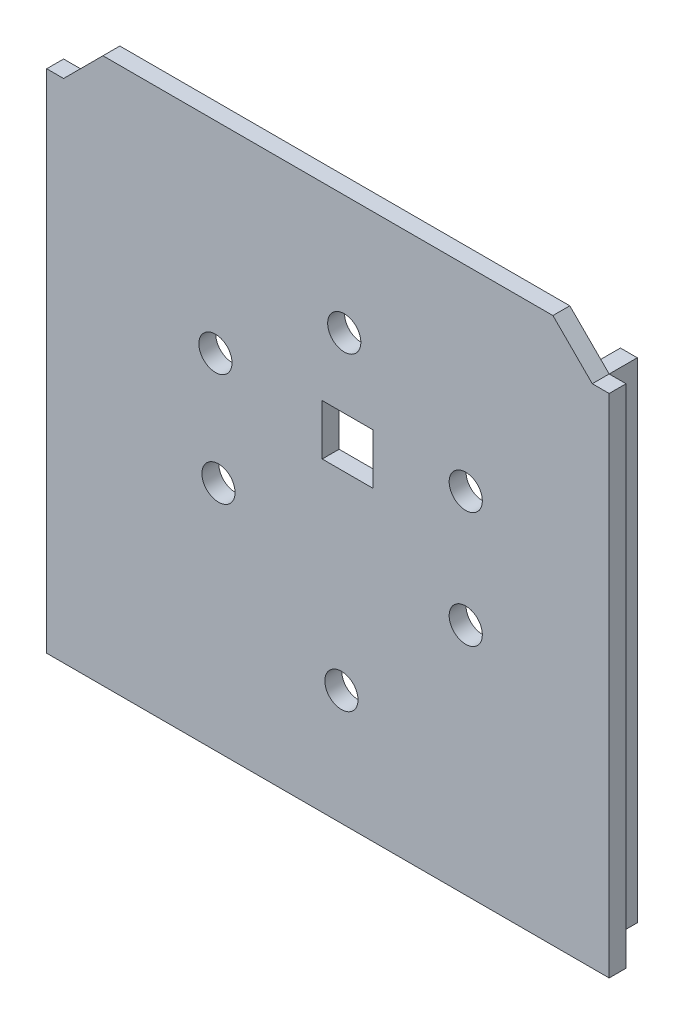
from build123d import *

# Parameters (mm, degrees)
CROQUIS1_R              = 2.950001172
CROQUIS1_W              = 9
CROQUIS1_H              = 9
SALIENTE_EXTRUIR1_DEPTH = 3
SALIENTE_EXTRUIR6_DEPTH = 5


with BuildPart() as part:
    # Croquis1 → Saliente-Extruir1 (new body)
    with BuildSketch(Plane.XY.offset(-0.156260387)):
        Polygon((51.261125499, 62.988673094), (44.261125499, 69.988673094), (-35.738874501, 69.988673094), (-42.738874501, 62.988673094), (-45.738874501, 62.988673094), (-45.738874501, -27.011326906), (54.261125499, -27.011326906), (54.261125499, 62.988673094), align=None)
        with Locations((7.161124531, 48.770443145)):
            Circle(CROQUIS1_R, mode=Mode.SUBTRACT)
        with Locations((28.761125092, 35.170443896)):
            Circle(CROQUIS1_R, mode=Mode.SUBTRACT)
        with Locations((28.761125092, 14.5704435)):
            Circle(CROQUIS1_R, mode=Mode.SUBTRACT)
        with Locations((6.661127243, -6.529559074)):
            Circle(CROQUIS1_R, mode=Mode.SUBTRACT)
        with Locations((-15.198872503, 14.470443669)):
            Circle(CROQUIS1_R, mode=Mode.SUBTRACT)
        with Locations((-15.738875683, 34.170445595)):
            Circle(CROQUIS1_R, mode=Mode.SUBTRACT)
        with Locations((7.748576734, 31.892113927)):
            Rectangle(CROQUIS1_W, CROQUIS1_H, mode=Mode.SUBTRACT)
    extrude(amount=SALIENTE_EXTRUIR1_DEPTH)

    # Croquis9 → Saliente-Extruir6 (add)
    with BuildSketch(Plane(origin=(0, 0, -0.156260387), x_dir=(-1, 0, 0), z_dir=(0, 0, -1))):
        Polygon((-51.261125499, 62.988673094), (-48.261125499, 62.988673094), (-48.261125499, -21.011326906), (39.738874501, -21.011326906), (39.738874501, 62.988673094), (42.738874501, 62.988673094), (42.738874501, -24.011326906), (-51.261125499, -24.011326906), align=None)
    extrude(amount=SALIENTE_EXTRUIR6_DEPTH)


solid = part.part
